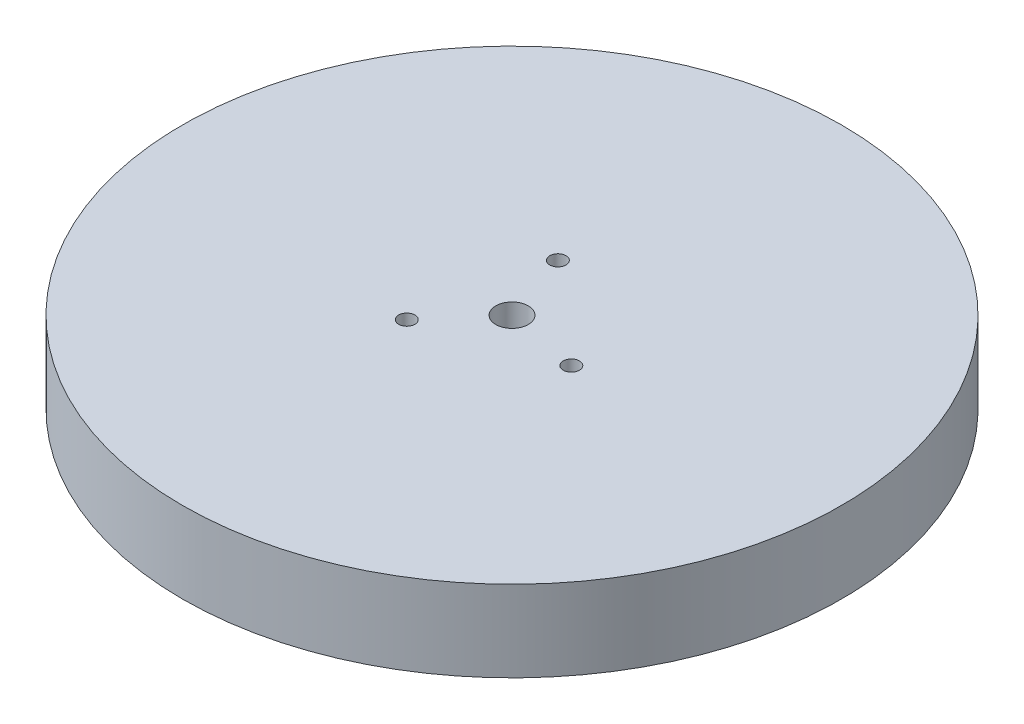
from build123d import *

# Parameters (mm, degrees)
SKETCH1_R           = 101.6
SKETCH1_R_2         = 5
BOSS_EXTRUDE8_DEPTH = 25
SKETCH2_R           = 2.5
CUT_EXTRUDE1_DEPTH  = 26


with BuildPart() as part:
    # Sketch1 → Boss-Extrude8 (new body)
    with BuildSketch(Plane(origin=(0, 0, 0), x_dir=(1, 0, 0), z_dir=(0, 1, 0))):
        Circle(SKETCH1_R)
        Circle(SKETCH1_R_2, mode=Mode.SUBTRACT)
    extrude(amount=BOSS_EXTRUDE8_DEPTH)

    # Sketch2 → Cut-Extrude1 (cut, through all)
    with BuildSketch(Plane.XZ):
        with Locations((22.59307321, 4.307324334)):
            Circle(SKETCH2_R)
        with Locations((-7.56628431, -21.719837517)):
            Circle(SKETCH2_R)
        with Locations((-15.026788901, 17.412513183)):
            Circle(SKETCH2_R)
    extrude(amount=-CUT_EXTRUDE1_DEPTH, mode=Mode.SUBTRACT)


solid = part.part
